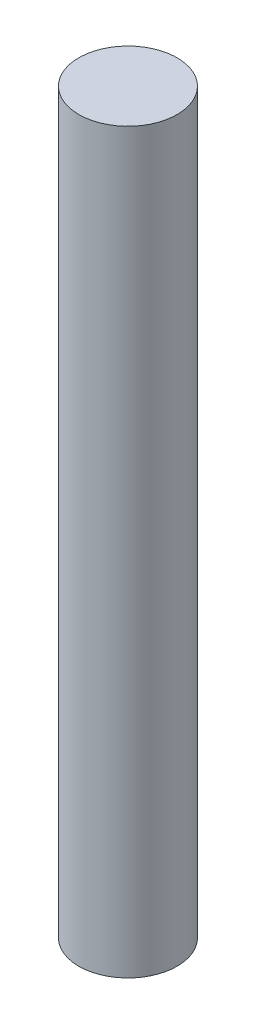
from build123d import *

# Parameters (mm, degrees)
SKETCH1_R           = 5.08
BOSS_EXTRUDE1_DEPTH = 76.2


with BuildPart() as part:
    # Sketch1 → Boss-Extrude1 (new body)
    with BuildSketch(Plane(origin=(0, 0, 0), x_dir=(1, 0, 0), z_dir=(0, 1, 0))):
        Circle(SKETCH1_R)
    extrude(amount=BOSS_EXTRUDE1_DEPTH)


solid = part.part
